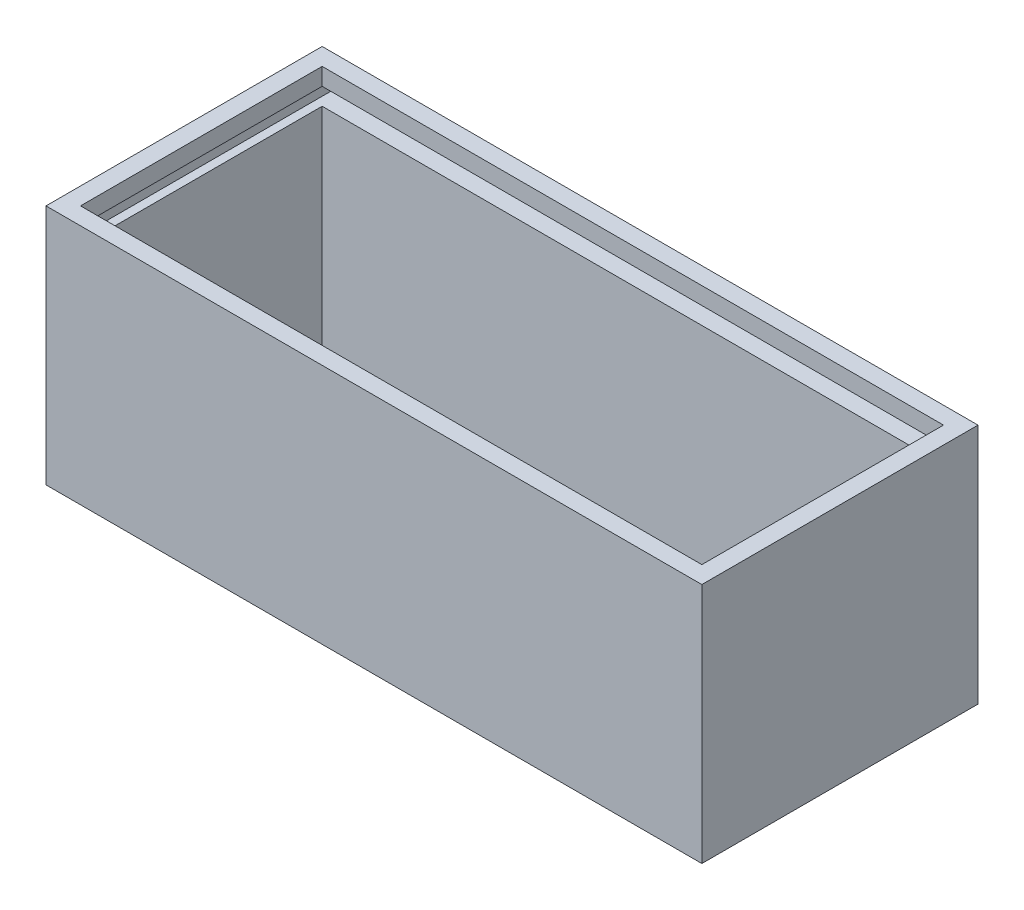
from build123d import *

# Parameters (mm, degrees)
SKETCH1_W           = 190
SKETCH1_H           = 80
SKETCH1_W_2         = 180
SKETCH1_H_2         = 70
BOSS_EXTRUDE2_DEPTH = 70
SKETCH5_W           = 185
SKETCH5_H           = 5
CUT_EXTRUDE2_DEPTH  = 75


with BuildPart() as part:
    # Sketch1 → Boss-Extrude2 (new body)
    with BuildSketch(Plane(origin=(0, 0, 0), x_dir=(1, 0, 0), z_dir=(0, 1, 0))):
        with Locations((95, 40)):
            Rectangle(SKETCH1_W, SKETCH1_H)
        with Locations((95, 40)):
            Rectangle(SKETCH1_W_2, SKETCH1_H_2, mode=Mode.SUBTRACT)
    extrude(amount=BOSS_EXTRUDE2_DEPTH)

    # Sketch5 → Cut-Extrude2 (cut)
    with BuildSketch(Plane(origin=(0, 0, -80), x_dir=(-1, 0, 0), z_dir=(0, 0, -1))):
        with Locations((-95, 62.5)):
            Rectangle(SKETCH5_W, SKETCH5_H)
    extrude(amount=-CUT_EXTRUDE2_DEPTH, mode=Mode.SUBTRACT)


solid = part.part
